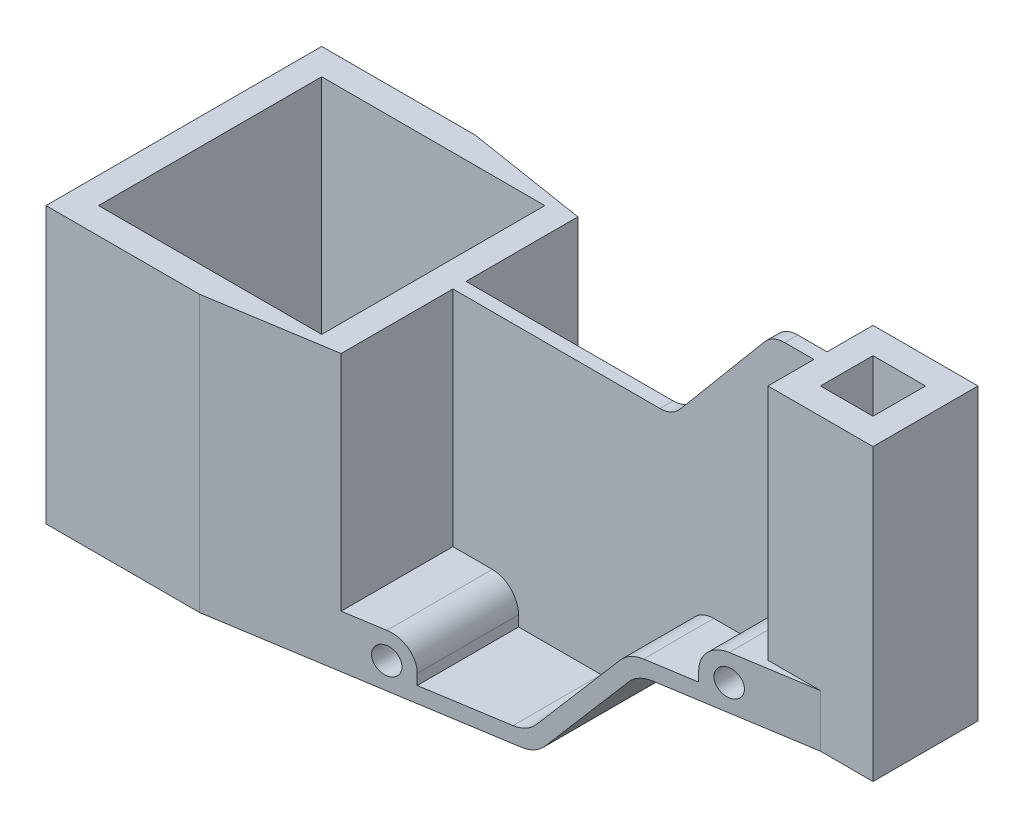
from build123d import *

# Parameters (mm, degrees)
ESQUISSE1_W                  = 52.5
ESQUISSE1_H                  = 105
BOSS_EXTRU_1_DEPTH           = 52.5
BOSS_EXTRU_2_DEPTH           = 45.5
BOSS_EXTRU_2_DEPTH_BACK      = 105
ESQUISSE2_W                  = 20
ESQUISSE2_H                  = 20
ESQUISSE2_3_W                = 85
ESQUISSE2_3_H                = 85
ENL_V_MAT_EXTRU_1_DEPTH      = 259.227128706
ENL_V_START                  = -2.5
ENL_V_MAT_EXTRU_3_DEPTH      = 278.332985904
ENL_V_START_2                = 2.5
ENL_V_MAT_EXTRU_4_DEPTH      = 278.332985904
ENL_V_MAT_EXTRU_5_DEPTH      = 280.832985904
ENL_V_MAT_EXTRU_5_DEPTH_BACK = 280.832985904
ESQUISSE1_6_R                = 5
ENL_V_START_3                = -20
ESQUISSE1_7_W                = 20
ESQUISSE1_7_H                = 90.5
ENL_V_MAT_EXTRU_6_DEPTH      = 32.5
ENL_V_START_4                = 20
ESQUISSE1_8_W                = 20
ESQUISSE1_8_H                = 90.5
ENL_V_MAT_EXTRU_7_DEPTH      = 32.5


with BuildPart() as part:
    # Esquisse1 → Boss.-Extru.1 (new, symmetric)
    with BuildSketch(Plane.XY):
        with Locations((-26.25, 52.5)):
            Rectangle(ESQUISSE1_W, ESQUISSE1_H)
    extrude(amount=BOSS_EXTRU_1_DEPTH, both=True)

    # Esquisse2 → Boss.-Extru.2 (add, two sides: drawn at the far end of the back side and taken through both)
    with BuildSketch(Plane(origin=(0, 105, 0), x_dir=(1, 0, 0), z_dir=(0, 1, 0)).offset(-BOSS_EXTRU_2_DEPTH_BACK)):
        Polygon((6, 52.5), (0, 52.5), (0, 42.5), (42.5, 42.5), (42.5, -42.5), (0, -42.5), (0, -52.5), (6, -52.5), (210, -20), (230, -20), (230, 20), (210, 20), align=None)
        with Locations((210, 0)):
            Rectangle(ESQUISSE2_W, ESQUISSE2_H, mode=Mode.SUBTRACT)
    extrude(amount=BOSS_EXTRU_2_DEPTH + BOSS_EXTRU_2_DEPTH_BACK)

    # Esquisse2_3 → Enl_v. mat.-Extru.1 (cut, through all)
    with BuildSketch(Plane(origin=(0, 105, 0), x_dir=(1, 0, 0), z_dir=(0, 1, 0))):
        Rectangle(ESQUISSE2_3_W, ESQUISSE2_3_H)
    extrude(amount=-ENL_V_MAT_EXTRU_1_DEPTH, mode=Mode.SUBTRACT)

    # Esquisse1_4 → Enl_v. mat.-Extru.3 (cut, through all)
    with BuildSketch(Plane.XY.offset(ENL_V_START)):
        with BuildLine():
            Line((52.5, 105), (52.5, 20))
            Line((52.5, 20), (67.5, 20))
            ThreePointArc((67.5, 20), (74.571067812, 17.071067812), (77.5, 10))
            Line((77.5, 10), (77.5, 6))
            Line((77.5, 6), (108.975092222, 6))
            ThreePointArc((108.975092222, 6), (113.20127484, 6.93692213), (116.635536654, 9.572123903))
            Line((116.635536654, 9.572123903), (144.204786201, 42.427876097))
            ThreePointArc((144.204786201, 42.427876097), (147.639048015, 45.06307787), (151.865230633, 46))
            Line((151.865230633, 46), (170, 46))
            Line((170, 46), (170, 50))
            ThreePointArc((170, 50), (172.928932188, 57.071067812), (180, 60))
            Line((180, 60), (190, 60))
            Line((190, 60), (190, 150.5))
            Line((190, 150.5), (178.849703137, 150.5))
            ThreePointArc((178.849703137, 150.5), (174.623520519, 149.56307787), (171.189258706, 146.927876097))
            Line((171.189258706, 146.927876097), (139.004961186, 108.572123903))
            ThreePointArc((139.004961186, 108.572123903), (135.570699372, 105.93692213), (131.344516755, 105))
            Line((131.344516755, 105), (52.5, 105))
        make_face()
    extrude(amount=-ENL_V_MAT_EXTRU_3_DEPTH, mode=Mode.SUBTRACT)

    # Esquisse1_5 → Enl_v. mat.-Extru.4 (cut, through all)
    with BuildSketch(Plane.XY.offset(ENL_V_START_2)):
        with BuildLine():
            Line((52.5, 105), (52.5, 20))
            Line((52.5, 20), (67.5, 20))
            ThreePointArc((67.5, 20), (74.571067812, 17.071067812), (77.5, 10))
            Line((77.5, 10), (77.5, 6))
            Line((77.5, 6), (108.975092222, 6))
            ThreePointArc((108.975092222, 6), (113.20127484, 6.93692213), (116.635536654, 9.572123903))
            Line((116.635536654, 9.572123903), (144.204786201, 42.427876097))
            ThreePointArc((144.204786201, 42.427876097), (147.639048015, 45.06307787), (151.865230633, 46))
            Line((151.865230633, 46), (170, 46))
            Line((170, 46), (170, 50))
            ThreePointArc((170, 50), (172.928932188, 57.071067812), (180, 60))
            Line((180, 60), (190, 60))
            Line((190, 60), (190, 150.5))
            Line((190, 150.5), (178.849703137, 150.5))
            ThreePointArc((178.849703137, 150.5), (174.623520519, 149.56307787), (171.189258706, 146.927876097))
            Line((171.189258706, 146.927876097), (139.004961186, 108.572123903))
            ThreePointArc((139.004961186, 108.572123903), (135.570699372, 105.93692213), (131.344516755, 105))
            Line((131.344516755, 105), (52.5, 105))
        make_face()
    extrude(amount=ENL_V_MAT_EXTRU_4_DEPTH, mode=Mode.SUBTRACT)

    # Esquisse1_6 → Enl_v. mat.-Extru.5 (cut, two sides: drawn at the far end of the back side and taken through both)
    with BuildSketch(Plane.XY.offset(-ENL_V_MAT_EXTRU_5_DEPTH_BACK)):
        with BuildLine():
            Line((0, 105), (131.344516755, 105))
            ThreePointArc((131.344516755, 105), (135.570699372, 105.93692213), (139.004961186, 108.572123903))
            Line((139.004961186, 108.572123903), (171.189258706, 146.927876097))
            ThreePointArc((171.189258706, 146.927876097), (174.623520519, 149.56307787), (178.849703137, 150.5))
            Line((178.849703137, 150.5), (0, 150.5))
            Line((0, 150.5), (0, 105))
        make_face()
        with BuildLine():
            ThreePointArc((119.433382603, 3.572123903), (115.999120789, 0.93692213), (111.772938171, 0))
            Line((111.772938171, 0), (230, 0))
            Line((230, 0), (230, 40))
            Line((230, 40), (154.663076582, 40))
            ThreePointArc((154.663076582, 40), (150.436893964, 39.06307787), (147.00263215, 36.427876097))
            Line((147.00263215, 36.427876097), (119.433382603, 3.572123903))
        make_face()
        with Locations((67.5, 10)):
            Circle(ESQUISSE1_6_R)
        with Locations((180, 50)):
            Circle(ESQUISSE1_6_R)
    extrude(amount=ENL_V_MAT_EXTRU_5_DEPTH + ENL_V_MAT_EXTRU_5_DEPTH_BACK, mode=Mode.SUBTRACT)

    # Esquisse1_7 → Enl_v. mat.-Extru.6 (cut)
    with BuildSketch(Plane.XY.offset(ENL_V_START_3)):
        with Locations((200, 105.25)):
            Rectangle(ESQUISSE1_7_W, ESQUISSE1_7_H)
    extrude(amount=-ENL_V_MAT_EXTRU_6_DEPTH, mode=Mode.SUBTRACT)

    # Esquisse1_8 → Enl_v. mat.-Extru.7 (cut)
    with BuildSketch(Plane.XY.offset(ENL_V_START_4)):
        with Locations((200, 105.25)):
            Rectangle(ESQUISSE1_8_W, ESQUISSE1_8_H)
    extrude(amount=ENL_V_MAT_EXTRU_7_DEPTH, mode=Mode.SUBTRACT)


solid = part.part
